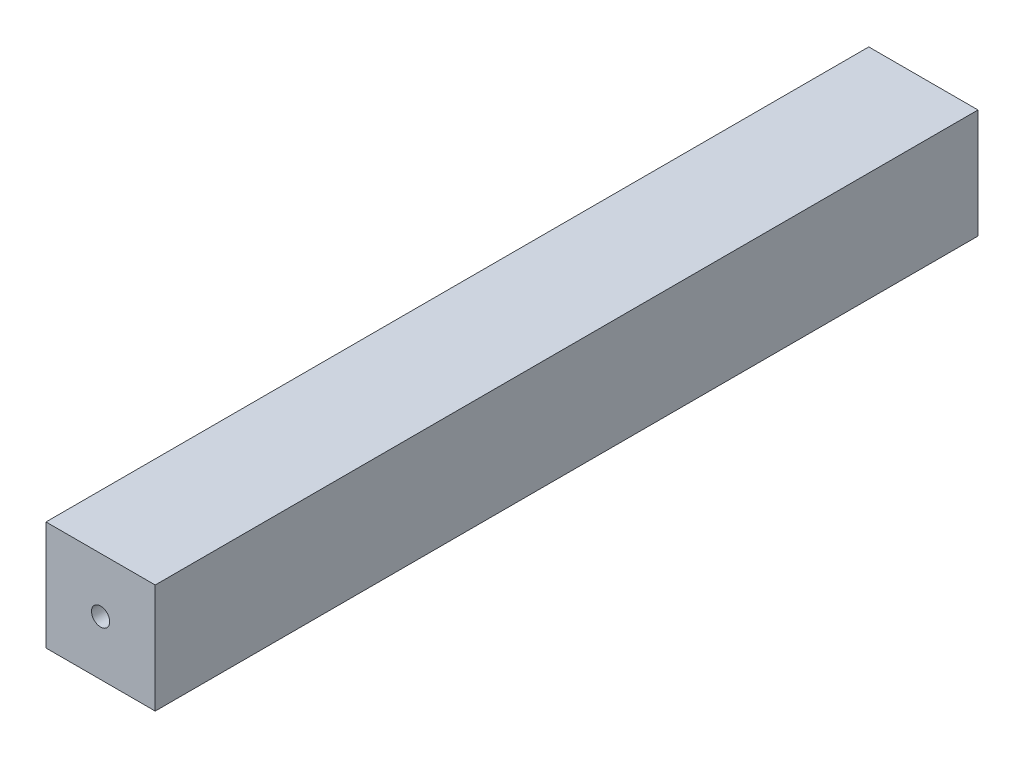
from build123d import *

# Parameters (mm, degrees)
ESQUISSE1_W        = 15
ESQUISSE1_H        = 15
ESQUISSE1_R        = 1.25
BOSS_EXTRU_1_DEPTH = 113


with BuildPart() as part:
    # Esquisse1 → Boss.-Extru.1 (new body)
    with BuildSketch(Plane.XY):
        with Locations((7.5, 7.5)):
            Rectangle(ESQUISSE1_W, ESQUISSE1_H)
        with Locations((7.5, 7.5)):
            Circle(ESQUISSE1_R, mode=Mode.SUBTRACT)
    extrude(amount=BOSS_EXTRU_1_DEPTH)


solid = part.part
